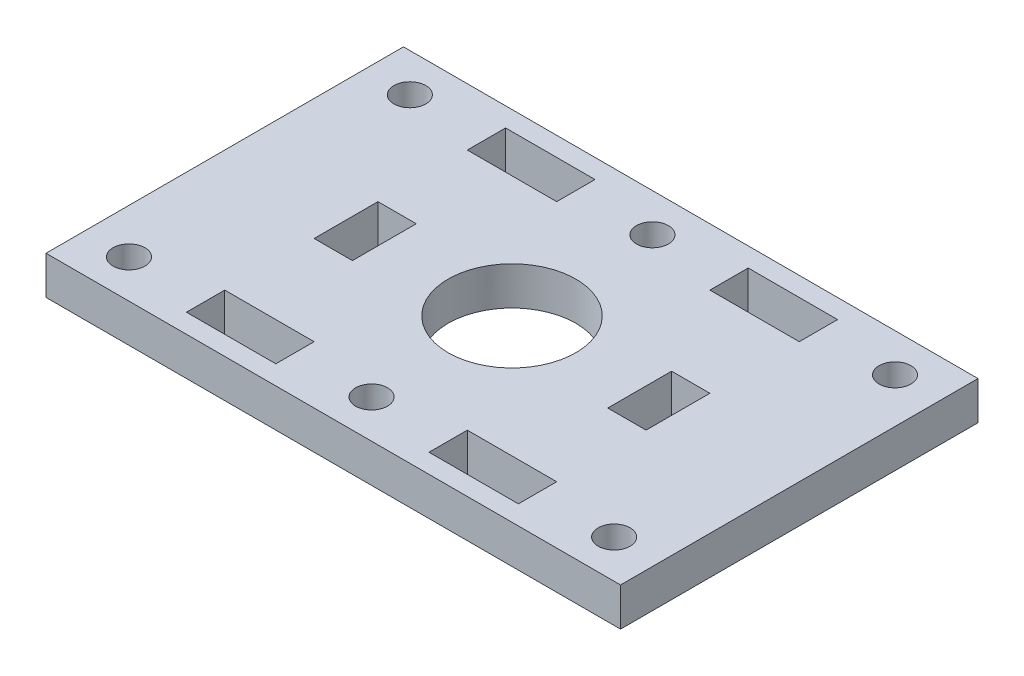
from build123d import *

# Parameters (mm, degrees)
SKETCH_1_W          = 45
SKETCH_1_H          = 28
EXTRUDE_1_DEPTH     = 3
SKETCH_2_R          = 1.25
SKETCH_2_W          = 7
SKETCH_2_H          = 3
CUT_EXTRUDE_1_DEPTH = 4
SKETCH_3_W          = 3
SKETCH_3_H          = 5
CUT_EXTRUDE_2_DEPTH = 4
SKETCH_4_R          = 5
CUT_EXTRUDE_3_DEPTH = 10


with BuildPart() as part:
    # 스케치1 → 보스-돌출1 (new body)
    with BuildSketch(Plane(origin=(0, 0, 0), x_dir=(1, 0, 0), z_dir=(0, 1, 0))):
        with Locations((22.5, 14)):
            Rectangle(SKETCH_1_W, SKETCH_1_H)
    extrude(amount=EXTRUDE_1_DEPTH)

    # 스케치2 → 컷-돌출1 (cut, through all)
    with BuildSketch(Plane(origin=(0, 3, 0), x_dir=(1, 0, 0), z_dir=(0, 1, 0))):
        with Locations((22.5, 3)):
            Circle(SKETCH_2_R)
        with Locations((22.5, 25)):
            Circle(SKETCH_2_R)
        with Locations((3.5, 3)):
            Circle(SKETCH_2_R)
        with Locations((41.5, 3)):
            Circle(SKETCH_2_R)
        with Locations((41.5, 25)):
            Circle(SKETCH_2_R)
        with Locations((3.5, 25)):
            Circle(SKETCH_2_R)
        with Locations((32, 3)):
            Rectangle(SKETCH_2_W, SKETCH_2_H)
        with Locations((13, 3)):
            Rectangle(SKETCH_2_W, SKETCH_2_H)
        with Locations((32, 25)):
            Rectangle(SKETCH_2_W, SKETCH_2_H)
        with Locations((13, 25)):
            Rectangle(SKETCH_2_W, SKETCH_2_H)
    extrude(amount=-CUT_EXTRUDE_1_DEPTH, mode=Mode.SUBTRACT)

    # 스케치3 → 컷-돌출2 (cut, through all)
    with BuildSketch(Plane(origin=(0, 3, 0), x_dir=(1, 0, 0), z_dir=(0, 1, 0))):
        with Locations((11, 14)):
            Rectangle(SKETCH_3_W, SKETCH_3_H)
        with Locations((34, 14)):
            Rectangle(SKETCH_3_W, SKETCH_3_H)
    extrude(amount=-CUT_EXTRUDE_2_DEPTH, mode=Mode.SUBTRACT)

    # 스케치4 → 컷-돌출3 (cut)
    with BuildSketch(Plane(origin=(0, 3, 0), x_dir=(1, 0, 0), z_dir=(0, 1, 0))):
        with Locations((22.5, 14)):
            Circle(SKETCH_4_R)
    extrude(amount=-CUT_EXTRUDE_3_DEPTH, mode=Mode.SUBTRACT)


solid = part.part
